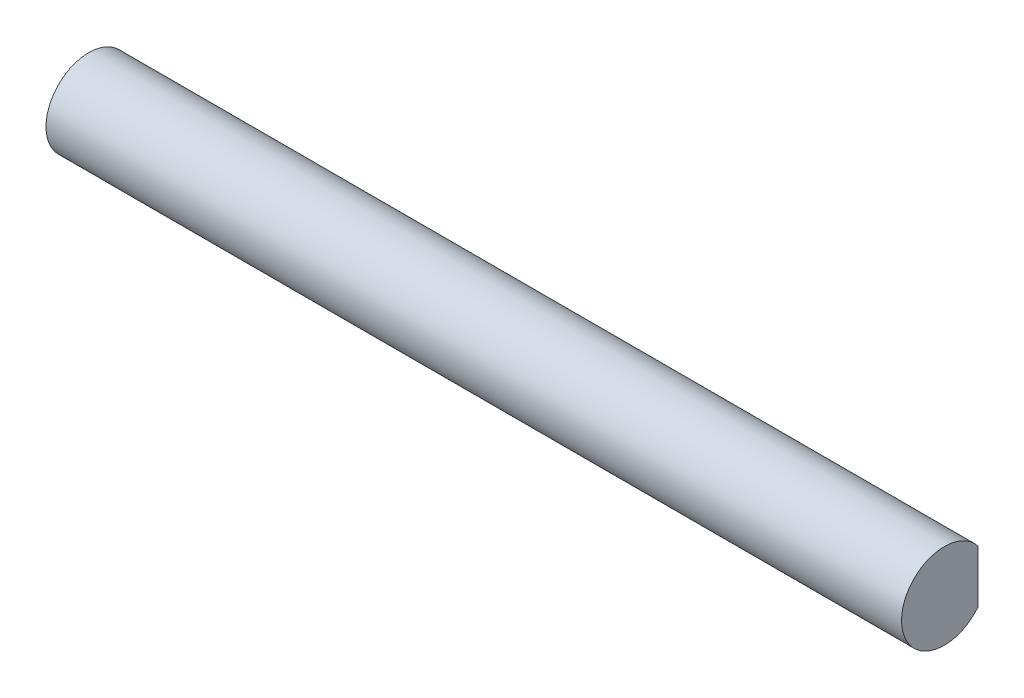
from build123d import *

# Parameters (mm, degrees)
BOSS_EXTRUDE1_DEPTH = 60


with BuildPart() as part:
    # Sketch1 → Boss-Extrude1 (new body)
    with BuildSketch(Plane(origin=(0, 0, 0), x_dir=(0, 0, -1), z_dir=(1, 0, 0))):
        with BuildLine():
            Line((2.361673136, 1.85), (2.361673136, -1.85))
            ThreePointArc((2.361673136, -1.85), (-3, 0), (2.361673136, 1.85))
        make_face()
    extrude(amount=BOSS_EXTRUDE1_DEPTH)


solid = part.part
